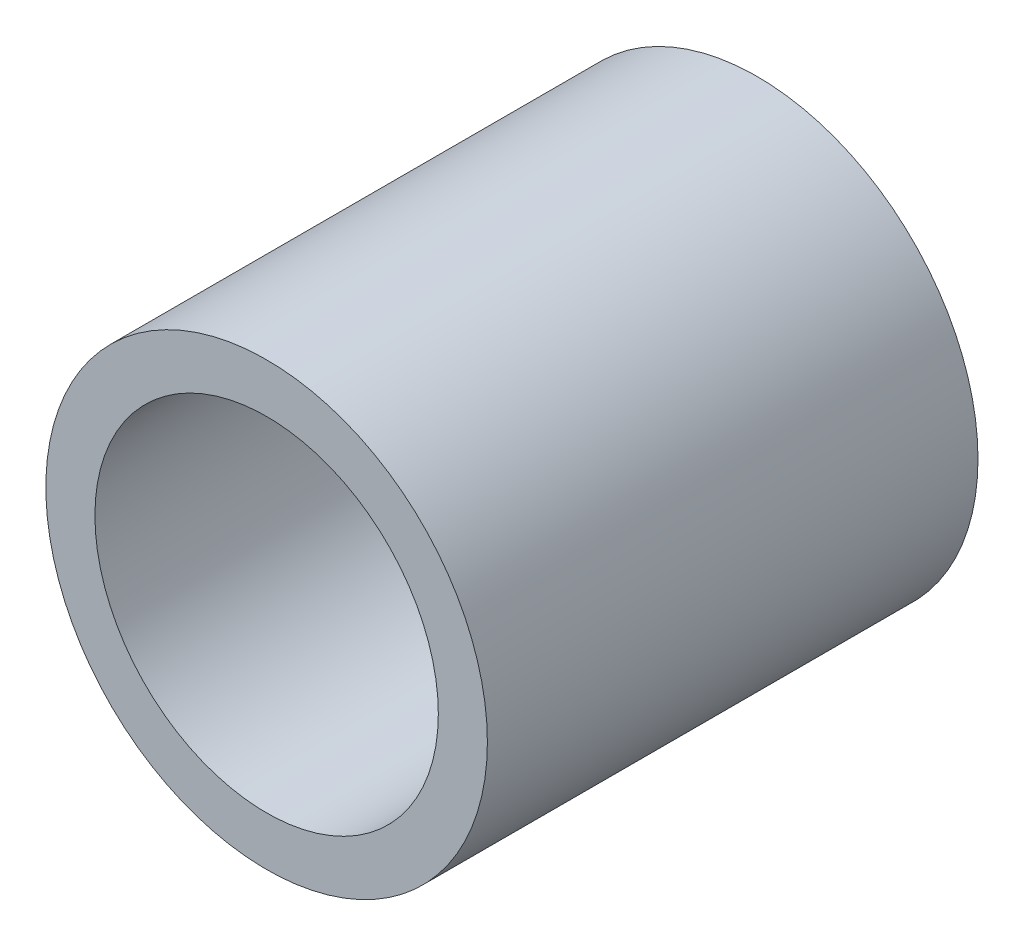
from build123d import *

# Parameters (mm, degrees)
SKETCH1_R      = 14.2875
SKETCH1_R_2    = 11.1125
EXTRUDE1_DEPTH = 15.875


with BuildPart() as part:
    # Sketch1 → Extrude1 (new body, symmetric)
    with BuildSketch(Plane.XY):
        Circle(SKETCH1_R)
        Circle(SKETCH1_R_2, mode=Mode.SUBTRACT)
    extrude(amount=EXTRUDE1_DEPTH, both=True)


solid = part.part
